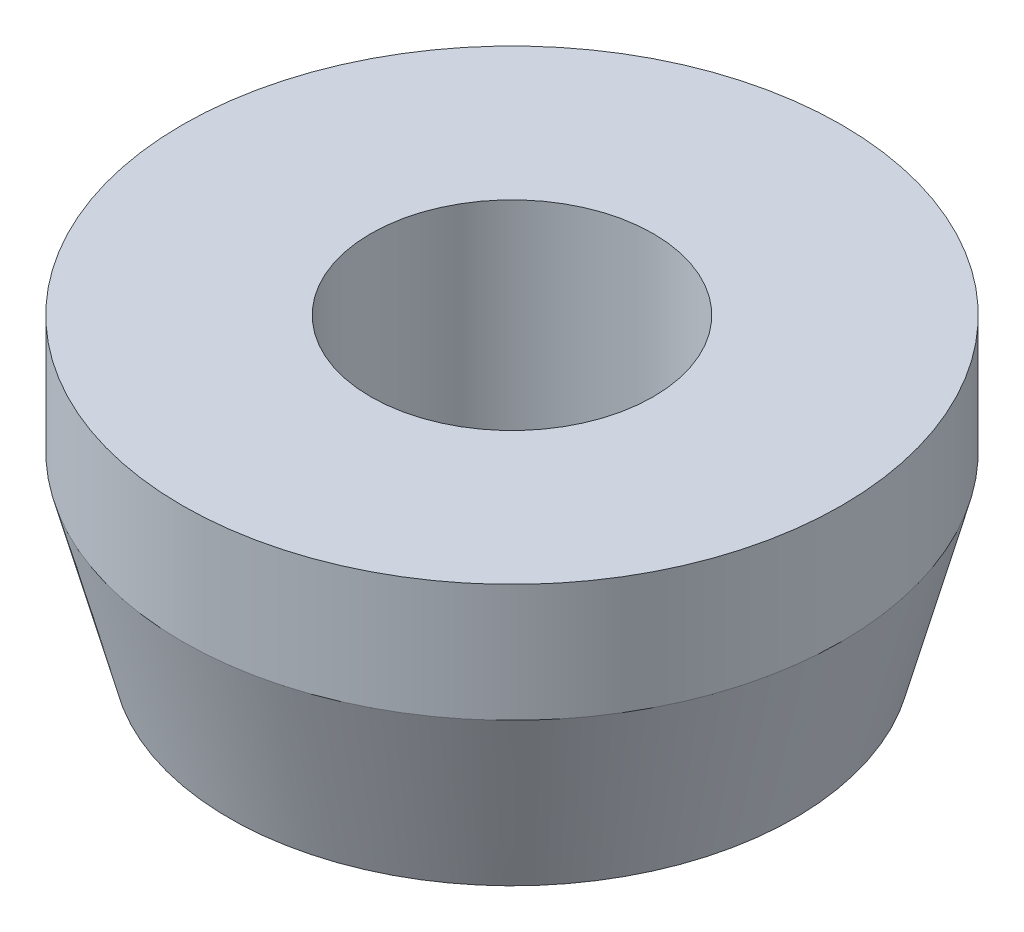
from build123d import *


with BuildPart() as part:
    # Sketch1 → Revolve1 (revolve)
    with BuildSketch(Plane.XY):
        Polygon((3.556, 1.905), (3.048, 0), (1.524, 0), (1.524, 3.175), (3.048, 3.175), (3.556, 3.175), align=None)
    revolve(axis=Axis((0, 0, 0), (0, 1, 0)))


solid = part.part
